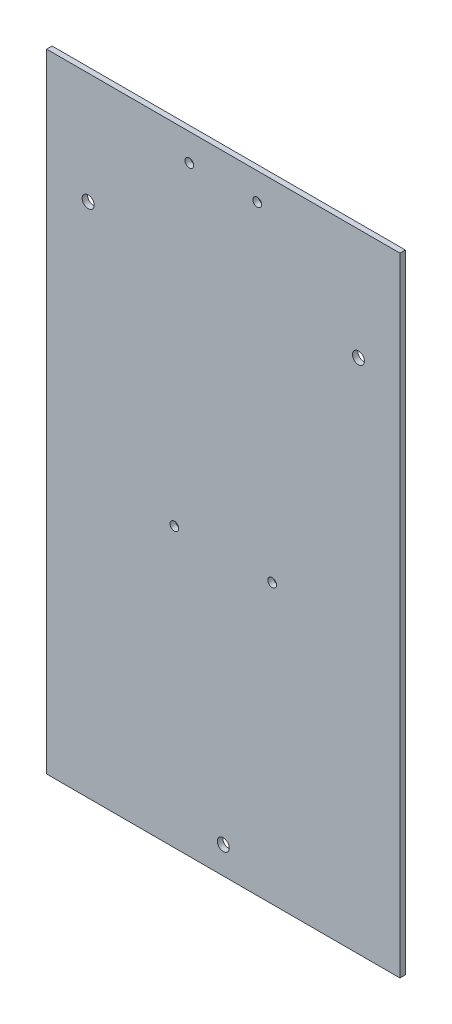
from build123d import *

# Parameters (mm, degrees)
SKETCH_1_W          = 150
SKETCH_1_H          = 231
EXTRUDE_1_DEPTH     = 2
SKETCH_2_R          = 2.2
CUT_EXTRUDE_1_DEPTH = 2
SKETCH_3_R          = 1.6
CUT_EXTRUDE_2_DEPTH = 10
SKETCH_4_W          = 2
SKETCH_4_H          = 231
CUT_EXTRUDE_3_DEPTH = 10
SKETCH_5_W          = 2
SKETCH_5_H          = 231
CUT_EXTRUDE_4_DEPTH = 10
SKETCH_6_R          = 1.6
CUT_EXTRUDE_5_DEPTH = 10


with BuildPart() as part:
    # ｽｹｯﾁ1 → ﾎﾞｽ - 押し出し1 (new body)
    with BuildSketch(Plane.XY):
        Rectangle(SKETCH_1_W, SKETCH_1_H)
    extrude(amount=EXTRUDE_1_DEPTH)

    # ｽｹｯﾁ2 → ｶｯﾄ - 押し出し1 (cut)
    with BuildSketch(Plane.XY.offset(2)):
        with Locations((49.73, 74.5)):
            Circle(SKETCH_2_R)
        with Locations((-49.73, 74.5)):
            Circle(SKETCH_2_R)
        with Locations((0, -105.5)):
            Circle(SKETCH_2_R)
    extrude(amount=-CUT_EXTRUDE_1_DEPTH, mode=Mode.SUBTRACT)

    # ｽｹｯﾁ3 → ｶｯﾄ - 押し出し2 (cut)
    with BuildSketch(Plane.XY.offset(2)):
        with Locations((-18, -13)):
            Circle(SKETCH_3_R)
        with Locations((18, -13)):
            Circle(SKETCH_3_R)
    extrude(amount=-CUT_EXTRUDE_2_DEPTH, mode=Mode.SUBTRACT)

    # ｽｹｯﾁ4 → ｶｯﾄ - 押し出し3 (cut)
    with BuildSketch(Plane.ZY.offset(75)):
        with Locations((1, 0)):
            Rectangle(SKETCH_4_W, SKETCH_4_H)
    extrude(amount=-CUT_EXTRUDE_3_DEPTH, mode=Mode.SUBTRACT)

    # ｽｹｯﾁ5 → ｶｯﾄ - 押し出し4 (cut)
    with BuildSketch(Plane(origin=(75, 0, 0), x_dir=(0, 0, -1), z_dir=(1, 0, 0))):
        with Locations((-1, 0)):
            Rectangle(SKETCH_5_W, SKETCH_5_H)
    extrude(amount=-CUT_EXTRUDE_4_DEPTH, mode=Mode.SUBTRACT)

    # ｽｹｯﾁ6 → ｶｯﾄ - 押し出し5 (cut)
    with BuildSketch(Plane(origin=(0, 0, 0), x_dir=(-1, 0, 0), z_dir=(0, 0, -1))):
        with Locations((-12.5, 105.5)):
            Circle(SKETCH_6_R)
        with Locations((12.5, 105.5)):
            Circle(SKETCH_6_R)
    extrude(amount=-CUT_EXTRUDE_5_DEPTH, mode=Mode.SUBTRACT)


solid = part.part
